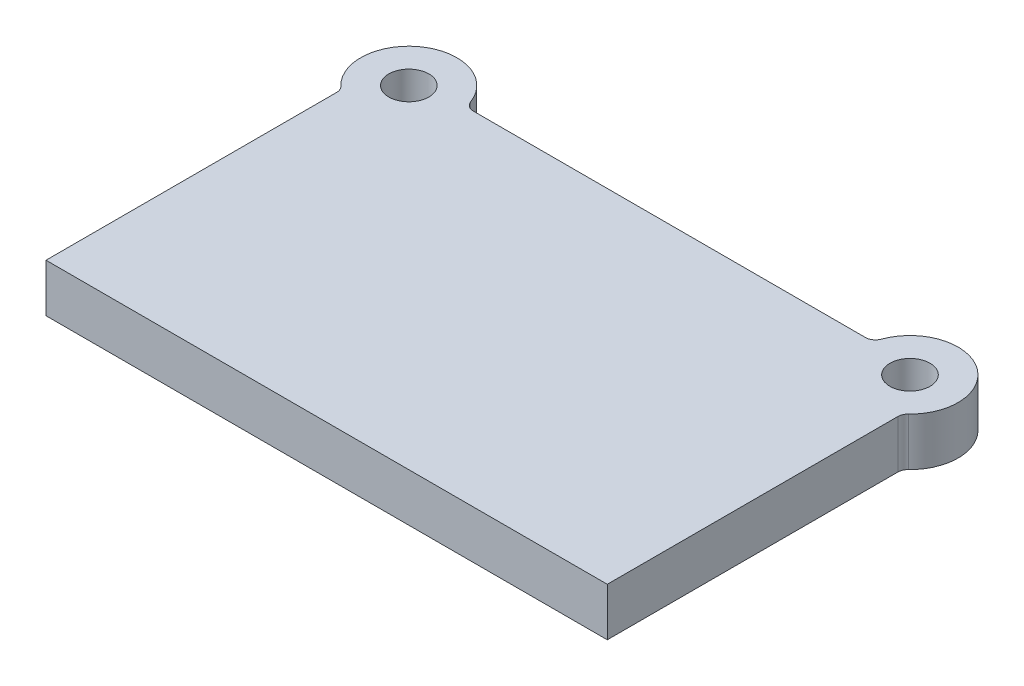
from build123d import *

# Parameters (mm, degrees)
SKETCH1_R           = 20
BOSS_EXTRUDE1_DEPTH = 48
FILLET1_R           = 10


with BuildPart() as part:
    # Sketch1 → Boss-Extrude1 (new body)
    with BuildSketch(Plane(origin=(0, 0, 0), x_dir=(1, 0, 0), z_dir=(0, 1, 0))):
        with BuildLine():
            Line((280, 0), (-280, 0))
            Line((-280, 0), (-280, 294.53001201))
            ThreePointArc((-280, 294.53001201), (-275.20214801, 372.851581802), (-203.053221623, 342))
            Line((-203.053221623, 342), (203.053221623, 342))
            ThreePointArc((203.053221623, 342), (275.20214801, 372.851581802), (280, 294.53001201))
            Line((280, 294.53001201), (280, 0))
        make_face()
        with Locations((-250, 332)):
            Circle(SKETCH1_R, mode=Mode.SUBTRACT)
        with Locations((250, 332)):
            Circle(SKETCH1_R, mode=Mode.SUBTRACT)
    extrude(amount=BOSS_EXTRUDE1_DEPTH)

    # Fillet1
    fillet1_edges = [part.edges().sort_by_distance(p)[0] for p in [
        (-280, 24, -294.53001201),
        (-203.053221623, 24, -342),
        (203.053221623, 24, -342),
        (280, 24, -294.53001201),
    ]]
    fillet(fillet1_edges, radius=FILLET1_R)


solid = part.part
